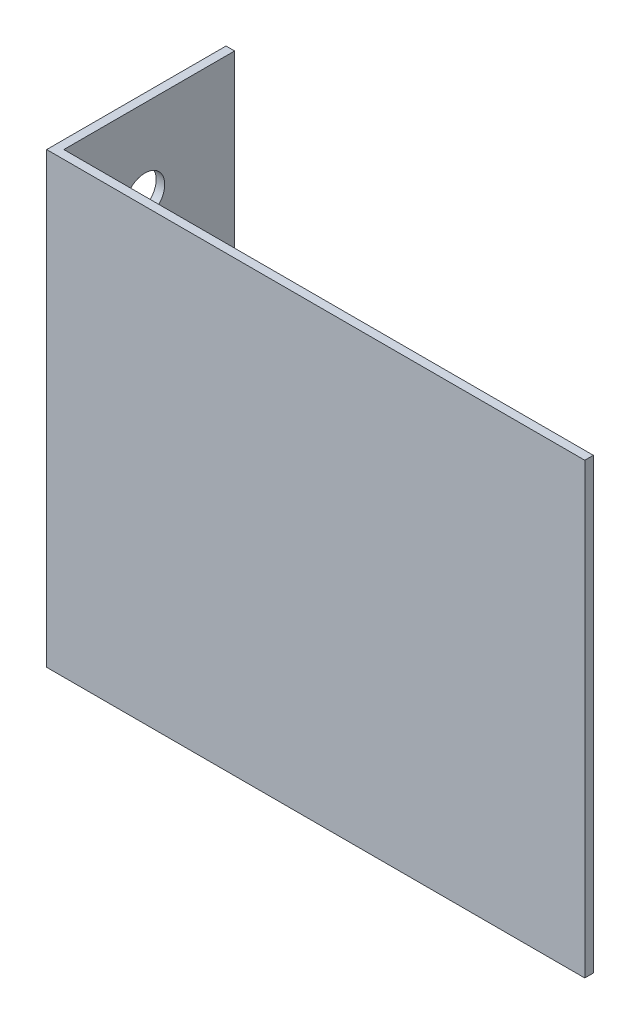
from build123d import *

# Parameters (mm, degrees)
BOSS_EXTRUDE1_DEPTH = 63.5
SKETCH3_R           = 2.8067
CUT_EXTRUDE1_DEPTH  = 2.54


with BuildPart() as part:
    # Sketch2 → Boss-Extrude1 (new body)
    with BuildSketch(Plane(origin=(0, 0, 0), x_dir=(1, 0, 0), z_dir=(0, 1, 0))):
        Polygon((0, 0), (0, 25.4), (1.21412, 25.4), (1.21412, 1.21412), (76.2, 1.21412), (76.2, 0), align=None)
    extrude(amount=BOSS_EXTRUDE1_DEPTH)

    # Sketch3 → Cut-Extrude1 (cut)
    with BuildSketch(Plane.ZY):
        with Locations((-12.7, 52.07)):
            Circle(SKETCH3_R)
        with Locations((-12.7, 11.43)):
            Circle(SKETCH3_R)
    extrude(amount=-CUT_EXTRUDE1_DEPTH, mode=Mode.SUBTRACT)


solid = part.part
